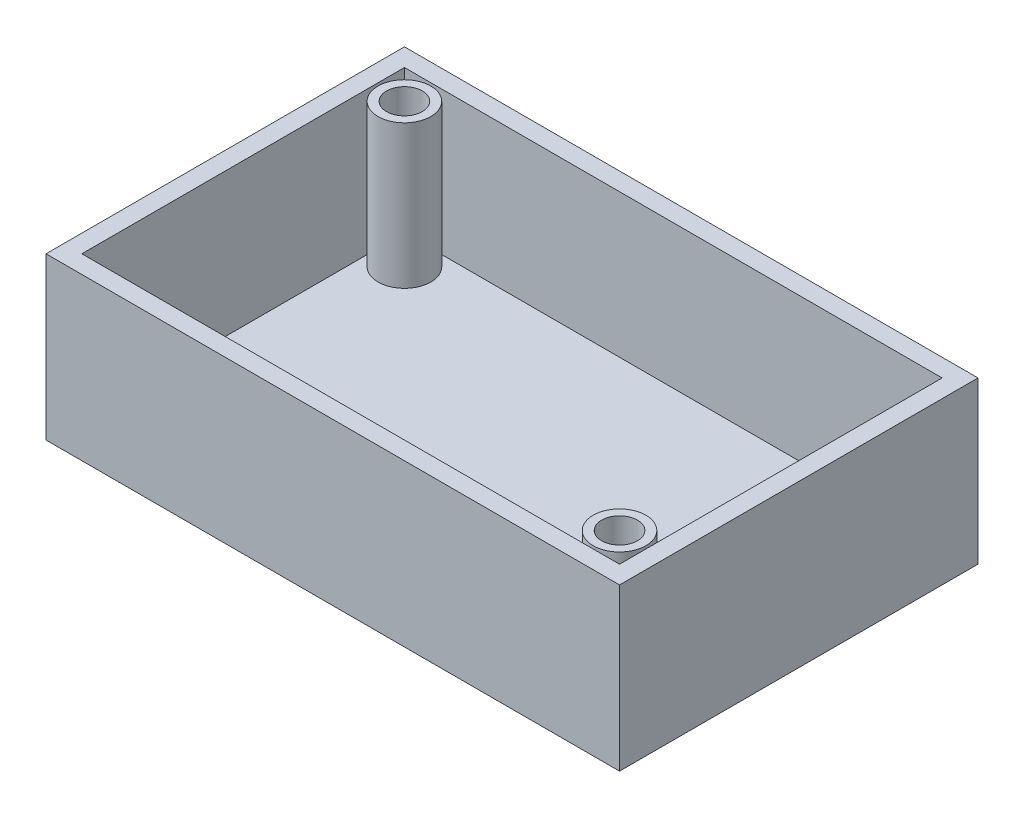
from build123d import *

# Parameters (mm, degrees)
SKETCH1_W           = 101.6
SKETCH1_H           = 63.5
BOSS_EXTRUDE1_DEPTH = 3.175
SKETCH2_W           = 101.6
SKETCH2_H           = 63.5
SKETCH2_W_2         = 95.25
SKETCH2_H_2         = 57.15
BOSS_EXTRUDE3_DEPTH = 25.4
SKETCH3_R           = 2.141141326
CUT_EXTRUDE1_DEPTH  = 3.175
SKETCH5_R           = 4.675
SKETCH5_R_2         = 3.175
BOSS_EXTRUDE4_DEPTH = 25.4


with BuildPart() as part:
    # Sketch1 → Boss-Extrude1 (new body)
    with BuildSketch(Plane(origin=(0, 0, 0), x_dir=(1, 0, 0), z_dir=(0, 1, 0))):
        with Locations((11.723076923, 23.795054945)):
            Rectangle(SKETCH1_W, SKETCH1_H)
    extrude(amount=BOSS_EXTRUDE1_DEPTH)

    # Sketch2 → Boss-Extrude3 (add)
    with BuildSketch(Plane(origin=(0, 3.175, 0), x_dir=(1, 0, 0), z_dir=(0, 1, 0))):
        with Locations((11.723076923, 23.795054945)):
            Rectangle(SKETCH2_W, SKETCH2_H)
        with Locations((11.723076923, 23.795054945)):
            Rectangle(SKETCH2_W_2, SKETCH2_H_2, mode=Mode.SUBTRACT)
    extrude(amount=BOSS_EXTRUDE3_DEPTH)

    # Sketch3 → Cut-Extrude1 (cut)
    with BuildSketch(Plane.XZ):
        with Locations((47.814406836, -23.777289581)):
            Circle(SKETCH3_R)
    extrude(amount=-CUT_EXTRUDE1_DEPTH, mode=Mode.SUBTRACT)

    # Sketch5 → Boss-Extrude4 (add)
    with BuildSketch(Plane(origin=(0, 3.175, 0), x_dir=(1, 0, 0), z_dir=(0, 1, 0))):
        with Locations((-30.726923077, 47.190054945)):
            Circle(SKETCH5_R)
        with Locations((-30.726923077, 47.190054945)):
            Circle(SKETCH5_R_2, mode=Mode.SUBTRACT)
        with Locations((54.168076923, 0.400054945)):
            Circle(SKETCH5_R)
        with Locations((54.168076923, 0.400054945)):
            Circle(SKETCH5_R_2, mode=Mode.SUBTRACT)
    extrude(amount=BOSS_EXTRUDE4_DEPTH)


solid = part.part
